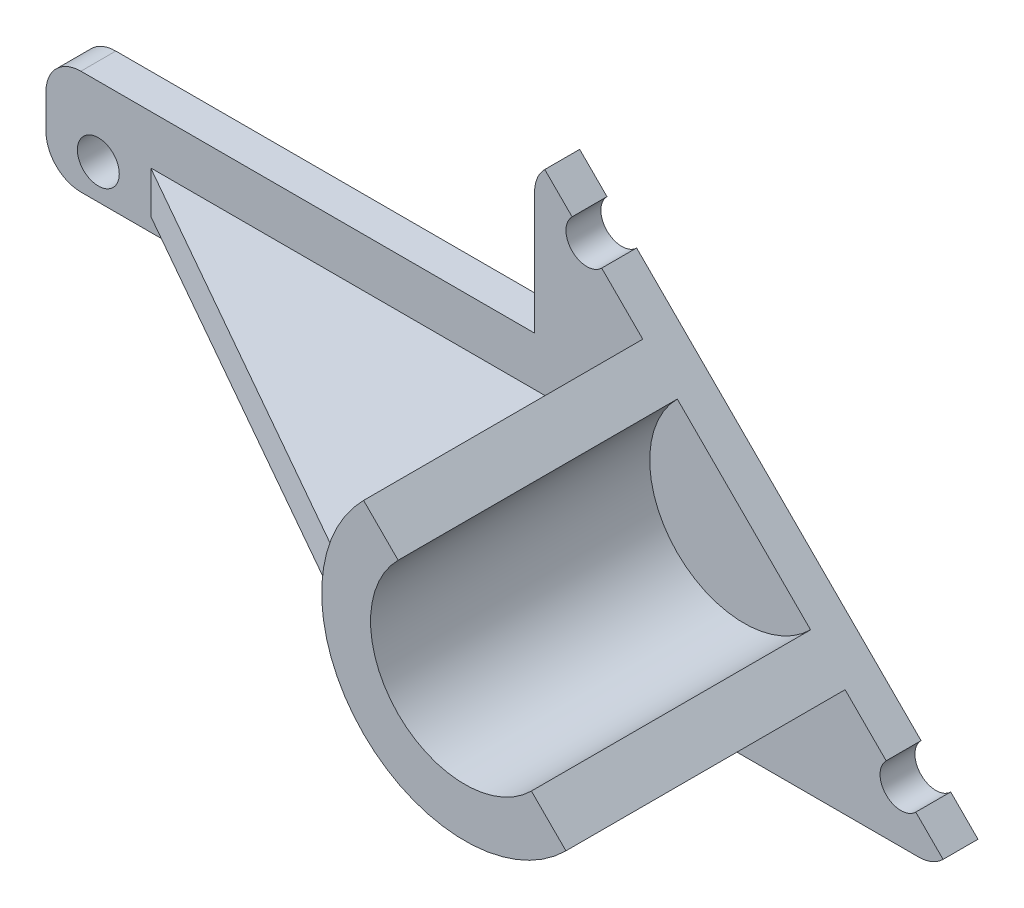
from build123d import *

# Parameters (mm, degrees)
SALIENTE_EXTRUIR1_DEPTH = 5
SALIENTE_EXTRUIR2_DEPTH = 40
EXTRUIR_L_MINA2_REACH   = 62.374
CROQUIS5_W              = 75.430750805
CROQUIS5_H              = 6
REDONDEO1_R             = 5
CROQUIS6_R              = 3
CORTAR_EXTRUIR1_DEPTH   = 40


with BuildPart() as part:
    # Croquis1 → Saliente-Extruir1 (new body)
    with BuildSketch(Plane.XY):
        with BuildLine():
            Line((-25, 16.317101546), (-95, 16.317101546))
            Line((-95, 16.317101546), (-95, 1.317101546))
            Line((-95, 1.317101546), (-25, 1.317101546))
            Line((-25, 1.317101546), (-25, -21.182898454))
            Line((-25, -21.182898454), (30, -21.182898454))
            ThreePointArc((30, -21.182898454), (31.913417162, -20.802296117), (33.535533906, -19.71843236))
            Line((33.535533906, -19.71843236), (-23.535533906, 37.352635452))
            ThreePointArc((-23.535533906, 37.352635452), (-24.619397663, 35.730518707), (-25, 33.817101546))
            Line((-25, 33.817101546), (-25, 16.317101546))
        make_face()
    extrude(amount=SALIENTE_EXTRUIR1_DEPTH)

    # Croquis2 → Saliente-Extruir2 (add)
    with BuildSketch(Plane.XY.offset(5)):
        with BuildLine():
            Line((-4.545941546, 18.363043092), (-9.495689014, 23.31279056))
            ThreePointArc((-9.495689014, 23.31279056), (-9.495689014, -5.678587469), (19.495689014, -5.678587469))
            Line((19.495689014, -5.678587469), (14.545941546, -0.72884))
            ThreePointArc((14.545941546, -0.72884), (-4.545941546, -0.72884), (-4.545941546, 18.363043092))
        make_face()
    extrude(amount=SALIENTE_EXTRUIR2_DEPTH)

    # Croquis5 → Extruir-Lámina2 (add, up to next)
    with BuildSketch(Plane(origin=(-21.625922377, 0, 38.118018916), x_dir=(0.869770425, 0, 0.493456592), z_dir=(-0.493456592, 0, 0.869770425)), mode=Mode.PRIVATE) as extruir_l_mina2_sk1:
        with Locations((-29.252830647, 6.317101546)):
            Rectangle(CROQUIS5_W, CROQUIS5_H)
    extruir_l_mina2_tool1 = extrude(extruir_l_mina2_sk1.sketch, amount=-EXTRUIR_L_MINA2_REACH, mode=Mode.PRIVATE) - part.part
    add(extruir_l_mina2_tool1.solids().sort_by_distance((-47.069169, 6.317102, 23.683017))[0])

    # Redondeo1
    redondeo1_edges = [part.edges().sort_by_distance(p)[0] for p in [
        (-95, 1.317101546, 2.5),
        (-95, 16.317101546, 2.5),
        (-25, -21.182898454, 2.5),
    ]]
    fillet(redondeo1_edges, radius=REDONDEO1_R)

    # Croquis6 → Cortar-Extruir1 (cut)
    with BuildSketch(Plane.XY.offset(5)):
        with Locations((-87.5, 6.317101546)):
            Circle(CROQUIS6_R)
        with Locations((-17.5, -13.682898454)):
            Circle(CROQUIS6_R)
        with Locations((-17.5, 31.317101546)):
            Circle(CROQUIS6_R)
        with Locations((27.5, -13.682898454)):
            Circle(CROQUIS6_R)
    extrude(amount=-CORTAR_EXTRUIR1_DEPTH, mode=Mode.SUBTRACT)


solid = part.part
